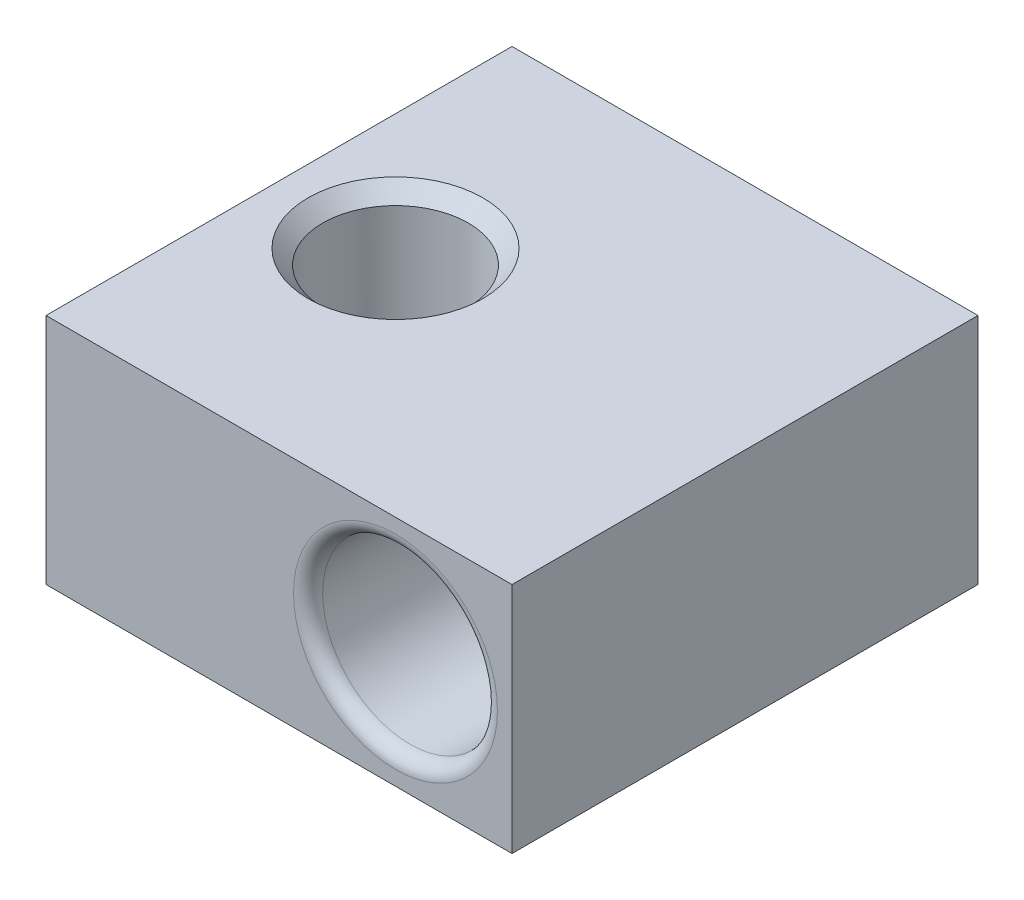
from build123d import *

# Parameters (mm, degrees)
ESQUISSE1_W             = 16
ESQUISSE1_H             = 8
ESQUISSE1_R             = 3
BOSS_EXTRU_1_DEPTH      = 16
ESQUISSE2_R             = 2.5
ENL_V_MAT_EXTRU_1_DEPTH = 9
CHANFREIN1_SIZE         = 0.5
CONG_1_R                = 0.5


with BuildPart() as part:
    # Esquisse1 → Boss.-Extru.1 (new body)
    with BuildSketch(Plane.XY):
        with Locations((8, 4)):
            Rectangle(ESQUISSE1_W, ESQUISSE1_H)
        with Locations((12, 4)):
            Circle(ESQUISSE1_R, mode=Mode.SUBTRACT)
    extrude(amount=BOSS_EXTRU_1_DEPTH)

    # Esquisse2 → Enlèv. mat.-Extru.1 (cut, through all)
    with BuildSketch(Plane(origin=(0, 8, 0), x_dir=(1, 0, 0), z_dir=(0, 1, 0))):
        with Locations((4, -8)):
            Circle(ESQUISSE2_R)
    extrude(amount=-ENL_V_MAT_EXTRU_1_DEPTH, mode=Mode.SUBTRACT)

    # Chanfrein1
    chanfrein1_edges = [part.edges().sort_by_distance(p)[0] for p in [
        (1.5, 0, 8),
        (1.5, 8, 8),
    ]]
    chamfer(chanfrein1_edges, length=CHANFREIN1_SIZE)

    # Congé1
    cong_1_edges = [part.edges().sort_by_distance(p)[0] for p in [
        (9, 4, 0),
        (9, 4, 16),
    ]]
    fillet(cong_1_edges, radius=CONG_1_R)


solid = part.part
